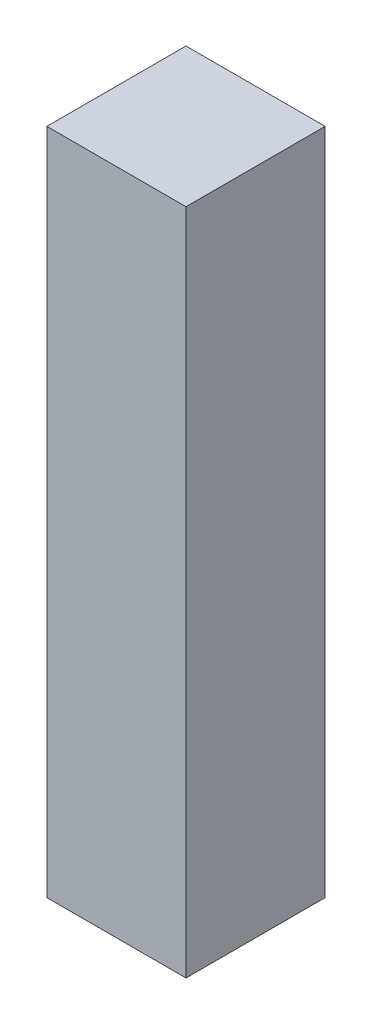
from build123d import *

# Parameters (mm, degrees)
SKETCH1_W           = 100
SKETCH1_H           = 480
BOSS_EXTRUDE1_DEPTH = 100


with BuildPart() as part:
    # Sketch1 → Boss-Extrude1 (new body)
    with BuildSketch(Plane.XY):
        with Locations((-50, 240)):
            Rectangle(SKETCH1_W, SKETCH1_H)
    extrude(amount=BOSS_EXTRUDE1_DEPTH)


solid = part.part
